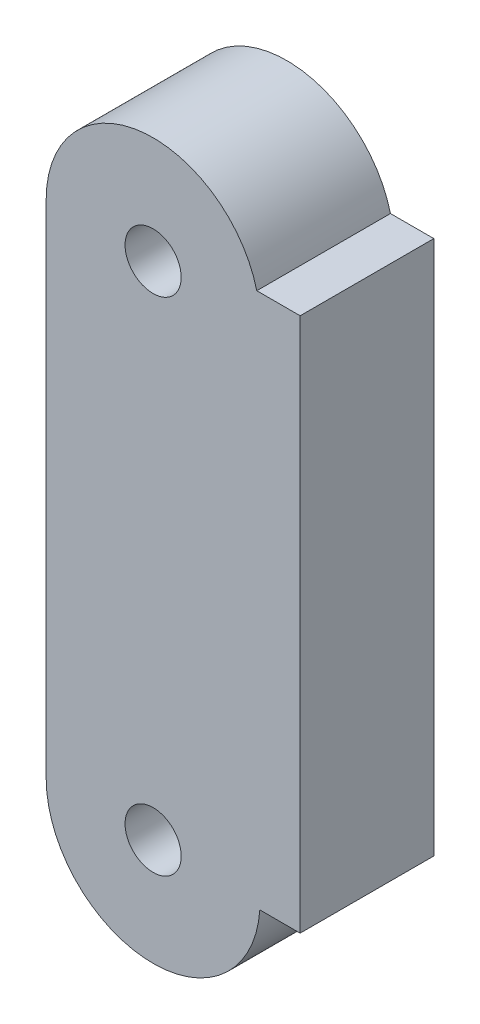
from build123d import *

# Parameters (mm, degrees)
CROQUIS1_R              = 2.1
SALIENTE_EXTRUIR1_DEPTH = 10


with BuildPart() as part:
    # Croquis1 → Saliente-Extruir1 (new body)
    with BuildSketch(Plane.XY):
        with BuildLine():
            Line((-3.244321048, 35), (0, 35))
            Line((0, 35), (0, -5))
            Line((0, -5), (-3.01811075, -5))
            ThreePointArc((-3.01811075, -5), (-11.269152373, -12.457471031), (-19, -4.462))
            Line((-19, -4.462), (-19, 33.038))
            ThreePointArc((-19, 33.038), (-11.988576853, 40.976684766), (-3.244321048, 35))
        make_face()
        with Locations((-11, -4.462)):
            Circle(CROQUIS1_R, mode=Mode.SUBTRACT)
        with Locations((-11, 33.038)):
            Circle(CROQUIS1_R, mode=Mode.SUBTRACT)
    extrude(amount=SALIENTE_EXTRUIR1_DEPTH)


solid = part.part
